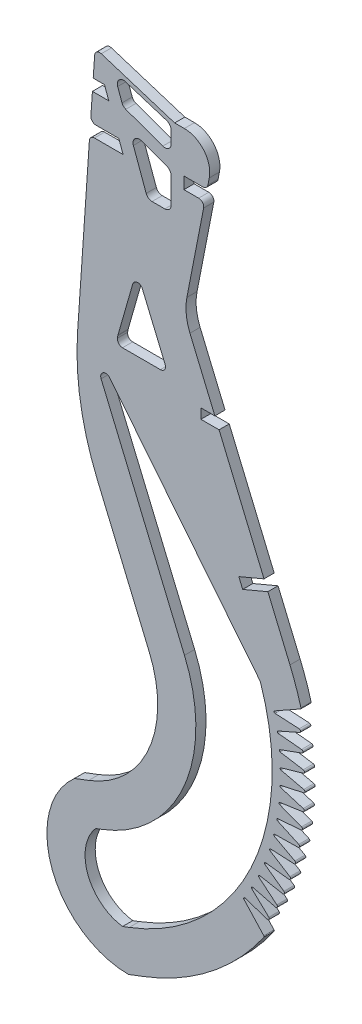
from build123d import *

# Parameters (mm, degrees)
BOSS_EXTRUDE1_DEPTH = 4
FILLET1_R           = 0.4
FILLET2_R           = 0.6


with BuildPart() as part:
    # Sketch1 → Boss-Extrude1 (new body)
    with BuildSketch(Plane.XY):
        with BuildLine():
            Line((-14.499129977, -6.867012113), (14.367174161, -16))
            Line((14.367174161, -16), (18.15387109, -16))
            ThreePointArc((18.15387109, -16), (25.872793622, -19.642466284), (27.968533139, -27.91635301))
            Line((27.968533139, -27.91635301), (27.439499229, -30.625816775))
            ThreePointArc((27.439499229, -30.625816775), (26.748073563, -31.786330679), (25.476566819, -32.242546173))
            Line((25.476566819, -32.242546173), (18, -32.242546173))
            Line((18, -32.242546173), (18, -36.892546173))
            Line((18, -36.892546173), (23.78761885, -36.892546173))
            ThreePointArc((23.78761885, -36.892546173), (25.331403357, -37.62103943), (25.75055126, -39.275816775))
            Line((25.75055126, -39.275816775), (19.168328866, -72.986875227))
            ThreePointArc((19.168328866, -72.986875227), (18.903762814, -78.877039551), (20.368176295, -84.588390014))
            Line((20.368176295, -84.588390014), (30.173934909, -107.85))
            Line((30.173934909, -107.85), (24.678215229, -107.85))
            Line((24.678215229, -107.85), (24.678215229, -111.75))
            Line((24.678215229, -111.75), (31.817950891, -111.75))
            Line((31.817950891, -111.75), (49.494630027, -153.683320214))
            Line((49.494630027, -153.683320214), (39.586931175, -157.859836948))
            Line((39.586931175, -157.859836948), (41.101848885, -161.453584898))
            Line((41.101848885, -161.453584898), (51.009547737, -157.277068164))
            Line((51.009547737, -157.277068164), (59.688079015, -177.864624701))
            ThreePointArc((59.688079015, -177.864624701), (62.10799078, -184.18292059), (64.103704557, -190.647745599))
            Line((64.103704557, -190.647745599), (52.448848585, -197.218781175))
            Line((52.448848585, -197.218781175), (65.808694789, -197.945888914))
            Line((65.808694789, -197.945888914), (53.567462973, -203.346483316))
            Line((53.567462973, -203.346483316), (66.884945667, -204.634439433))
            Line((66.884945667, -204.634439433), (54.312217418, -209.210538279))
            Line((54.312217418, -209.210538279), (67.514830834, -211.379679878))
            Line((67.514830834, -211.379679878), (54.666068058, -215.111096686))
            Line((54.666068058, -215.111096686), (67.695571684, -218.151855063))
            Line((67.695571684, -218.151855063), (54.627453954, -221.022129484))
            Line((54.627453954, -221.022129484), (67.42637092, -224.921090983))
            Line((67.42637092, -224.921090983), (54.196545445, -226.917561415))
            Line((54.196545445, -226.917561415), (66.708416062, -231.657526599))
            Line((66.708416062, -231.657526599), (53.375243393, -232.771386039))
            Line((53.375243393, -232.771386039), (65.544874215, -238.331445565))
            Line((65.544874215, -238.331445565), (52.167170795, -238.557780459))
            Line((52.167170795, -238.557780459), (63.940878095, -244.913407312))
            Line((63.940878095, -244.913407312), (50.577656806, -244.251219233))
            Line((50.577656806, -244.251219233), (61.903503389, -251.374376921))
            Line((61.903503389, -251.374376921), (48.613713227, -249.826586971))
            Line((48.613713227, -249.826586971), (59.44173754, -257.685853206))
            Line((59.44173754, -257.685853206), (46.284003576, -255.259289128))
            Line((46.284003576, -255.259289128), (56.566440102, -263.819994437))
            Line((56.566440102, -263.819994437), (43.59880487, -260.525360501))
            Line((43.59880487, -260.525360501), (53.290294836, -269.749741158))
            Line((53.290294836, -269.749741158), (40.569962289, -265.601570939))
            Line((40.569962289, -265.601570939), (49.627753757, -275.448935561))
            ThreePointArc((49.627753757, -275.448935561), (28.558785484, -297.812941794), (1.785859605, -312.888108085))
            Line((1.785859605, -312.888108085), (-3.79713943, -315))
            ThreePointArc((-3.79713943, -315), (-33.79713943, -294.273546964), (-25.025440375, -258.880847842))
            Line((-25.025440375, -258.880847842), (-19.44244134, -256.768955927))
            ThreePointArc((-19.44244134, -256.768955927), (4.29821428, -234.038615683), (4.399649005, -201.171051004))
            Line((4.399649005, -201.171051004), (-16.026093015, -152.716294646))
            ThreePointArc((-16.026093015, -152.716294646), (-22.647715731, -129.865425568), (-23.795753165, -106.102216294))
            Line((-23.795753165, -106.102216294), (-19.167544676, -38.755425513))
            ThreePointArc((-19.167544676, -38.755425513), (-18.537124111, -37.430656759), (-17.172250732, -36.892546173))
            Line((-17.172250732, -36.892546173), (-5.905128728, -36.892546173))
            Line((-5.905128728, -36.892546173), (-7.597590317, -32.242546173))
            Line((-7.597590317, -32.242546173), (-16.577805132, -32.242546173))
            ThreePointArc((-16.577805132, -32.242546173), (-18.039694546, -31.607419552), (-18.573099077, -30.105425513))
            Line((-18.573099077, -30.105425513), (-17.975910939, -21.415517819))
            Line((-17.975910939, -21.415517819), (-11.538306364, -21.415517819))
            Line((-11.538306364, -21.415517819), (-13.230767953, -16.765517819))
            Line((-13.230767953, -16.765517819), (-17.656353478, -16.765517819))
            Line((-17.656353478, -16.765517819), (-17.097726509, -8.636728098))
            ThreePointArc((-17.097726509, -8.636728098), (-16.228213916, -7.12078604), (-14.499129977, -6.867012113))
        make_face()
        with BuildLine():
            Line((-8.039189398, -14.802148248), (-6.329088682, -19.500611352))
            ThreePointArc((-6.329088682, -19.500611352), (-5.759253375, -20.395073615), (-4.864791112, -20.964908922))
            Line((-4.864791112, -20.964908922), (9.662050649, -26.252246921))
            ThreePointArc((9.662050649, -26.252246921), (11.905262269, -25.956922509), (12.95, -23.95))
            Line((12.95, -23.95), (12.95, -19.101392708))
            ThreePointArc((12.95, -19.101392708), (12.476507259, -17.653663778), (11.23904567, -16.765517819))
            Line((11.23904567, -16.765517819), (-4.997896808, -11.628324008))
            ThreePointArc((-4.997896808, -11.628324008), (-7.505894036, -12.269114715), (-8.039189398, -14.802148248))
        make_face(mode=Mode.SUBTRACT)
        with BuildLine():
            Line((-1.8643328, -31.767427321), (3.165925841, -45.587949351))
            ThreePointArc((3.165925841, -45.587949351), (4.062910493, -46.756922509), (5.468172762, -47.2))
            Line((5.468172762, -47.2), (10.5, -47.2))
            ThreePointArc((10.5, -47.2), (12.232411614, -46.482411614), (12.95, -44.75))
            Line((12.95, -44.75), (12.95, -34.591777725))
            ThreePointArc((12.95, -34.591777725), (12.506922509, -33.186515456), (11.337949351, -32.289530804))
            Line((11.337949351, -32.289530804), (1.275863472, -28.627231049))
            ThreePointArc((1.275863472, -28.627231049), (-1.294497493, -29.197066356), (-1.8643328, -31.767427321))
        make_face(mode=Mode.SUBTRACT)
        with BuildLine():
            Line((1.657284816, -78.8176291), (10.596301358, -100.023119123))
            ThreePointArc((10.596301358, -100.023119123), (10.419751266, -101.905947161), (8.753353691, -102.8))
            Line((8.753353691, -102.8), (-6.141789596, -102.8))
            ThreePointArc((-6.141789596, -102.8), (-7.654833819, -102.107936229), (-8.120754951, -100.510697178))
            ThreePointArc((-8.120754951, -100.510697178), (-8.05444857, -100.065191098), (-7.985836627, -99.620034266))
            ThreePointArc((-7.985836627, -99.620034266), (-7.962968981, -99.498759801), (-7.932665095, -99.379126613))
            Line((-7.932665095, -99.379126613), (-2.108355103, -79.043824493))
            ThreePointArc((-2.108355103, -79.043824493), (-0.305583194, -77.598108436), (1.657284816, -78.8176291))
        make_face(mode=Mode.SUBTRACT)
        with BuildLine():
            Line((-3.521215631, -298.858320046), (-6.119790114, -299.841287875))
            ThreePointArc((-6.119790114, -299.841287875), (-19.76735139, -288.966471728), (-16.733940587, -271.781711796))
            Line((-16.733940587, -271.781711796), (-14.135366104, -270.798743967))
            ThreePointArc((-14.135366104, -270.798743967), (18.084095095, -239.950425064), (18.221756508, -195.344444428))
            Line((18.221756508, -195.344444428), (-14.560581286, -117.576880877))
            ThreePointArc((-14.560581286, -117.576880877), (-13.741730826, -115.082087048), (-11.157717662, -115.548336225))
            Line((-11.157717662, -115.548336225), (47.774811887, -188.994412647))
            ThreePointArc((47.774811887, -188.994412647), (47.968900833, -189.285104624), (48.109417057, -189.605147645))
            ThreePointArc((48.109417057, -189.605147645), (44.356574969, -254.657971176), (-3.521215631, -298.858320046))
        make_face(mode=Mode.SUBTRACT)
    extrude(amount=BOSS_EXTRUDE1_DEPTH)

    # Fillet1
    fillet1_edges = [part.edges().sort_by_distance(p)[0] for p in [
        (64.103704557, -190.647745599, 2),
        (49.627753757, -275.448935561, 2),
        (40.569962289, -265.601570939, 2),
        (43.59880487, -260.525360501, 2),
        (46.284003576, -255.259289128, 2),
        (48.613713227, -249.826586971, 2),
        (50.577656806, -244.251219233, 2),
        (52.167170795, -238.557780459, 2),
        (53.375243393, -232.771386039, 2),
        (54.196545445, -226.917561415, 2),
        (54.627453954, -221.022129484, 2),
        (54.666068058, -215.111096686, 2),
        (54.312217418, -209.210538279, 2),
        (53.567462973, -203.346483316, 2),
        (52.448848585, -197.218781175, 2),
    ]]
    fillet(fillet1_edges, radius=FILLET1_R)

    # Fillet2
    fillet2_edges = [part.edges().sort_by_distance(p)[0] for p in [
        (53.290294836, -269.749741158, 2),
        (56.566440102, -263.819994437, 2),
        (59.44173754, -257.685853206, 2),
        (61.903503389, -251.374376921, 2),
        (63.940878095, -244.913407312, 2),
        (65.544874215, -238.331445565, 2),
        (66.708416062, -231.657526599, 2),
        (67.42637092, -224.921090983, 2),
        (67.695571684, -218.151855063, 2),
        (67.514830834, -211.379679878, 2),
        (66.884945667, -204.634439433, 2),
        (65.808694789, -197.945888914, 2),
    ]]
    fillet(fillet2_edges, radius=FILLET2_R)


solid = part.part
